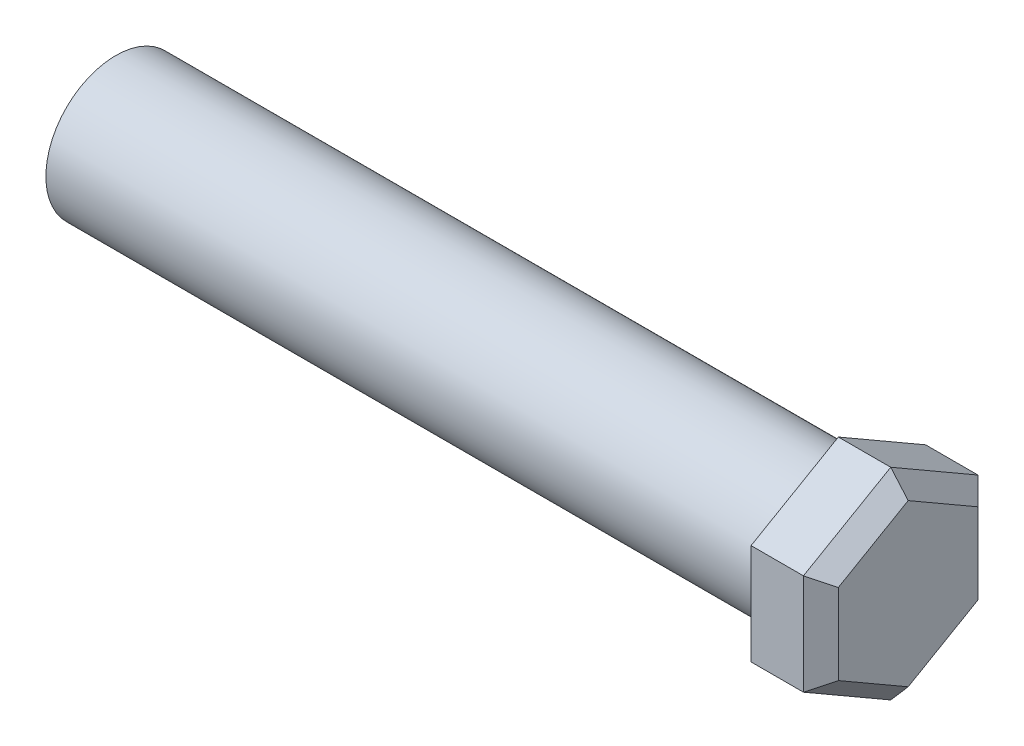
from build123d import *

# Parameters (mm, degrees)
SKETCH1_R           = 2
BOSS_EXTRUDE1_DEPTH = 20.7
BOSS_EXTRUDE2_DEPTH = 2
CHAMFER1_SIZE       = 0.5


with BuildPart() as part:
    # Sketch1 → Boss-Extrude1 (new body)
    with BuildSketch(Plane(origin=(0, 0, 0), x_dir=(0, 0, -1), z_dir=(1, 0, 0))):
        Circle(SKETCH1_R)
    extrude(amount=BOSS_EXTRUDE1_DEPTH)

    # Sketch2 → Boss-Extrude2 (add)
    with BuildSketch(Plane(origin=(20.7, 0, 0), x_dir=(0, 0, -1), z_dir=(1, 0, 0))):
        Polygon((0, -2.886751346), (2.5, -1.443375673), (2.5, 1.443375673), (0, 2.886751346), (-2.5, 1.443375673), (-2.5, -1.443375673), align=None)
    extrude(amount=BOSS_EXTRUDE2_DEPTH)

    # Chamfer1
    chamfer1_edges = [part.edges().sort_by_distance(p)[0] for p in [
        (22.7, -2.165063509, 1.25),
        (22.7, -2.165063509, -1.25),
        (22.7, 0, -2.5),
        (22.7, 2.165063509, -1.25),
        (22.7, 2.165063509, 1.25),
        (22.7, 0, 2.5),
    ]]
    chamfer(chamfer1_edges, length=CHAMFER1_SIZE)


solid = part.part
